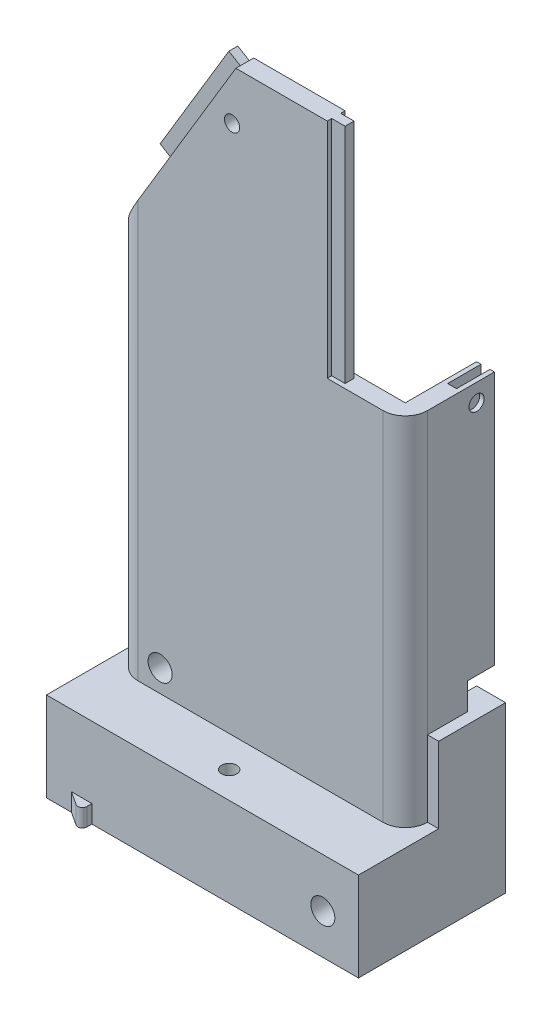
from build123d import *

# Parameters (mm, degrees)
SKETCH1_W                = 65
SKETCH1_H                = 40
BOSS_EXTRUDE1_DEPTH      = 130
SHELL1_T                 = -4
FILLET1_R                = 5
CUT_EXTRUDE1_DEPTH       = 21
CUT_EXTRUDE1_DEPTH_BACK  = 21
SKETCH3_W                = 17.5
SKETCH3_H                = 50
CUT_EXTRUDE2_DEPTH       = 21
CUT_EXTRUDE2_DEPTH_BACK  = 21
SKETCH5_W                = 2
SKETCH5_H                = 50
BOSS_EXTRUDE2_DEPTH      = 3
SKETCH6_W                = 2
SKETCH6_H                = 30
BOSS_EXTRUDE3_DEPTH      = 3
SKETCH8_W                = 70
SKETCH8_H                = 66
BOSS_EXTRUDE4_DEPTH      = 20
SKETCH10_W               = 60
SKETCH10_H               = 12
CUT_EXTRUDE4_DEPTH       = 45
SKETCH23_W               = 2
SKETCH23_H               = 15
CUT_EXTRUDE10_DEPTH      = 10
CUT_EXTRUDE11_START      = -10
SKETCH24_R               = 1.7
CUT_EXTRUDE11_DEPTH      = 13.5
SKETCH27_W               = 70
SKETCH27_H               = 33
CUT_EXTRUDE12_DEPTH      = 132.543487266
CUT_EXTRUDE12_DEPTH_BACK = 21
SKETCH31_R               = 2.7
CUT_EXTRUDE13_DEPTH      = 1
CUT_EXTRUDE13_DEPTH_BACK = 34
SKETCH34_R               = 1.7
CUT_EXTRUDE15_DEPTH      = 132.543487266
CUT_EXTRUDE15_DEPTH_BACK = 21
SKETCH37_W               = 6
SKETCH37_H               = 6
CUT_EXTRUDE17_DEPTH      = 3.5
CUT_EXTRUDE17_DEPTH_BACK = 68.5
SKETCH38_W               = 15
SKETCH38_H               = 17
BOSS_EXTRUDE9_DEPTH      = 2.5
SKETCH41_R               = 4
CUT_EXTRUDE18_DEPTH      = 2.4
SKETCH42_W               = 4.6
SKETCH42_H               = 4
BOSS_EXTRUDE10_DEPTH     = 3
CUT_EXTRUDE19_DEPTH      = 5
FILLET2_R                = 1
SKETCH46_R               = 1.7
CUT_EXTRUDE20_DEPTH      = 10
SKETCH50_W               = 15
SKETCH50_H               = 15
BOSS_EXTRUDE11_DEPTH     = 16
SKETCH51_R               = 2.7
CUT_EXTRUDE21_DEPTH      = 16.153953894
CUT_EXTRUDE21_DEPTH_BACK = 21


with BuildPart() as part:
    # Sketch1 → Boss-Extrude1 (new body)
    with BuildSketch(Plane(origin=(0, 0, 0), x_dir=(1, 0, 0), z_dir=(0, 1, 0))):
        Rectangle(SKETCH1_W, SKETCH1_H)
    extrude(amount=BOSS_EXTRUDE1_DEPTH)

    # Shell1
    shell1_openings = [part.faces().sort_by_distance(p)[0] for p in [
        (0, 130, 0),
        (0, 0, 0),
    ]]
    offset(amount=SHELL1_T, openings=shell1_openings, kind=Kind.INTERSECTION)

    # Fillet1
    fillet1_edges = [part.edges().sort_by_distance(p)[0] for p in [
        (32.5, 65, 20),
        (-32.5, 65, 20),
        (-32.5, 65, -20),
        (32.5, 65, -20),
    ]]
    fillet(fillet1_edges, radius=FILLET1_R)

    # Sketch2 → Cut-Extrude1 (cut, two sides)
    with BuildSketch(Plane.XY) as cut_extrude1_sk:
        Polygon((-5.5, 130), (-32.5, 85), (-32.5, 130), align=None)
    extrude(amount=CUT_EXTRUDE1_DEPTH, mode=Mode.SUBTRACT)
    extrude(cut_extrude1_sk.sketch, amount=-CUT_EXTRUDE1_DEPTH_BACK, mode=Mode.SUBTRACT)

    # Sketch3 → Cut-Extrude2 (cut, two sides)
    with BuildSketch(Plane.XY) as cut_extrude2_sk:
        with Locations((23.75, 105)):
            Rectangle(SKETCH3_W, SKETCH3_H)
    extrude(amount=CUT_EXTRUDE2_DEPTH, mode=Mode.SUBTRACT)
    extrude(cut_extrude2_sk.sketch, amount=-CUT_EXTRUDE2_DEPTH_BACK, mode=Mode.SUBTRACT)

    # Sketch5 → Boss-Extrude2 (add)
    with BuildSketch(Plane(origin=(15, 0, 0), x_dir=(0, 0, -1), z_dir=(1, 0, 0))):
        with Locations((-18, 105)):
            Rectangle(SKETCH5_W, SKETCH5_H)
    boss_extrude2 = extrude(amount=BOSS_EXTRUDE2_DEPTH)

    # Mirror1: Boss-Extrude2 across plane
    add(boss_extrude2.mirror(Plane.XY))

    # Sketch6 → Boss-Extrude3 (add)
    with BuildSketch(Plane(origin=(-61.397058824, 36.838235294, 0), x_dir=(0, 0, 1), z_dir=(-0.857492926, 0.514495755, 0))):
        with Locations((-18, 93.644353688)):
            Rectangle(SKETCH6_W, SKETCH6_H)
    boss_extrude3 = extrude(amount=BOSS_EXTRUDE3_DEPTH)

    # Mirror2: Boss-Extrude3 across plane
    add(boss_extrude3.mirror(Plane.XY))

    # Sketch8 → Boss-Extrude4 (add)
    with BuildSketch(Plane(origin=(0, 0, 0), x_dir=(1, 0, 0), z_dir=(0, 1, 0))):
        Rectangle(SKETCH8_W, SKETCH8_H)
    extrude(amount=-BOSS_EXTRUDE4_DEPTH)

    # Sketch10 → Cut-Extrude4 (cut)
    with BuildSketch(Plane.ZY.offset(35)):
        with Locations((0, -10)):
            Rectangle(SKETCH10_W, SKETCH10_H)
    extrude(amount=-CUT_EXTRUDE4_DEPTH, mode=Mode.SUBTRACT)

    # Sketch23 → Cut-Extrude10 (cut)
    with BuildSketch(Plane(origin=(0, 80, 0), x_dir=(1, 0, 0), z_dir=(0, 1, 0))):
        with Locations((30.5, 0)):
            Rectangle(SKETCH23_W, SKETCH23_H)
    extrude(amount=-CUT_EXTRUDE10_DEPTH, mode=Mode.SUBTRACT)

    # Sketch24 → Cut-Extrude11 (cut)
    with BuildSketch(Plane(origin=(32.5, 0, 0), x_dir=(0, 0, -1), z_dir=(1, 0, 0)).offset(CUT_EXTRUDE11_START)):
        with Locations((-4, 76)):
            Circle(SKETCH24_R)
    cut_extrude11 = extrude(amount=CUT_EXTRUDE11_DEPTH, mode=Mode.SUBTRACT)

    # Mirror4: Cut-Extrude11 across plane
    add(cut_extrude11.mirror(Plane.XY), mode=Mode.SUBTRACT)

    # Sketch27 → Cut-Extrude12 (cut, two sides)
    with BuildSketch(Plane(origin=(0, 0, 0), x_dir=(1, 0, 0), z_dir=(0, 1, 0))) as cut_extrude12_sk:
        with Locations((0, 16.5)):
            Rectangle(SKETCH27_W, SKETCH27_H)
    extrude(amount=CUT_EXTRUDE12_DEPTH, mode=Mode.SUBTRACT)
    extrude(cut_extrude12_sk.sketch, amount=-CUT_EXTRUDE12_DEPTH_BACK, mode=Mode.SUBTRACT)

    # Sketch31 → Cut-Extrude13 (cut, two sides)
    with BuildSketch(Plane.XY.offset(33)) as cut_extrude13_sk:
        with Locations((27, -11)):
            Circle(SKETCH31_R)
    extrude(amount=CUT_EXTRUDE13_DEPTH, mode=Mode.SUBTRACT)
    extrude(cut_extrude13_sk.sketch, amount=-CUT_EXTRUDE13_DEPTH_BACK, mode=Mode.SUBTRACT)

    # Sketch34 → Cut-Extrude15 (cut, two sides)
    with BuildSketch(Plane(origin=(0, 0, 0), x_dir=(1, 0, 0), z_dir=(0, 1, 0))) as cut_extrude15_sk:
        with Locations((0, -27)):
            Circle(SKETCH34_R)
    extrude(amount=CUT_EXTRUDE15_DEPTH, mode=Mode.SUBTRACT)
    extrude(cut_extrude15_sk.sketch, amount=-CUT_EXTRUDE15_DEPTH_BACK, mode=Mode.SUBTRACT)

    # Sketch37 → Cut-Extrude17 (cut, two sides)
    with BuildSketch(Plane(origin=(32.5, 0, 0), x_dir=(0, 0, -1), z_dir=(1, 0, 0))) as cut_extrude17_sk:
        with Locations((-3, 20)):
            Rectangle(SKETCH37_W, SKETCH37_H)
    extrude(amount=CUT_EXTRUDE17_DEPTH, mode=Mode.SUBTRACT)
    extrude(cut_extrude17_sk.sketch, amount=-CUT_EXTRUDE17_DEPTH_BACK, mode=Mode.SUBTRACT)

    # Sketch38 → Boss-Extrude9 (add)
    with BuildSketch(Plane(origin=(32.5, 0, 0), x_dir=(0, 0, -1), z_dir=(1, 0, 0))):
        with Locations((-7.5, 8.5)):
            Rectangle(SKETCH38_W, SKETCH38_H)
    extrude(amount=BOSS_EXTRUDE9_DEPTH)

    # Sketch41 → Cut-Extrude18 (cut)
    with BuildSketch(Plane(origin=(0, -20, 0), x_dir=(-1, 0, 0), z_dir=(0, -1, 0))):
        with Locations((0, -27)):
            Circle(SKETCH41_R)
    extrude(amount=-CUT_EXTRUDE18_DEPTH, mode=Mode.SUBTRACT)

    # Sketch42 → Boss-Extrude10 (add)
    with BuildSketch(Plane.XY.offset(33)):
        with Locations((-27.1, -18)):
            Rectangle(SKETCH42_W, SKETCH42_H)
    extrude(amount=BOSS_EXTRUDE10_DEPTH)

    # Sketch43 → Cut-Extrude19 (cut, through all)
    with BuildSketch(Plane(origin=(0, -16, 0), x_dir=(1, 0, 0), z_dir=(0, 1, 0))):
        Polygon((-24.8, -36), (-29.4, -33), (-29.4, -36), align=None)
    extrude(amount=-CUT_EXTRUDE19_DEPTH, mode=Mode.SUBTRACT)

    # Fillet2
    fillet2_edges = [part.edges().sort_by_distance(p)[0] for p in [
        (-24.8, -18, 36),
    ]]
    fillet(fillet2_edges, radius=FILLET2_R)

    # Sketch46 → Cut-Extrude20 (cut)
    with BuildSketch(Plane.XY.offset(20)):
        with Locations((-6.357492926, 118.852591966)):
            Circle(SKETCH46_R)
    extrude(amount=-CUT_EXTRUDE20_DEPTH, mode=Mode.SUBTRACT)

    # Sketch50 → Boss-Extrude11 (add)
    with BuildSketch(Plane(origin=(0, 0, 16), x_dir=(-1, 0, 0), z_dir=(0, 0, -1))):
        with Locations((21, 7.5)):
            Rectangle(SKETCH50_W, SKETCH50_H)
    extrude(amount=BOSS_EXTRUDE11_DEPTH)

    # Sketch51 → Cut-Extrude21 (cut, two sides)
    with BuildSketch(Plane.XY.offset(20)) as cut_extrude21_sk:
        with Locations((-22.5, 5)):
            Circle(SKETCH51_R)
    extrude(amount=CUT_EXTRUDE21_DEPTH, mode=Mode.SUBTRACT)
    extrude(cut_extrude21_sk.sketch, amount=-CUT_EXTRUDE21_DEPTH_BACK, mode=Mode.SUBTRACT)


solid = part.part
